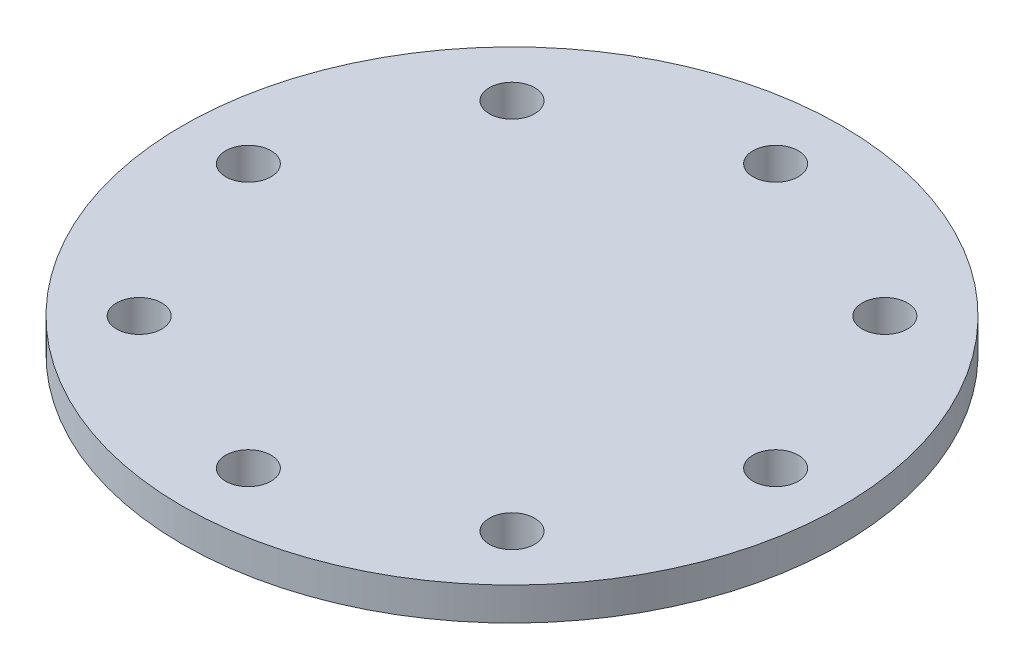
from build123d import *

# Parameters (mm, degrees)
SKETCH2_R                       = 127
EXTRUDE1_DEPTH                  = 12.7
F_11_16_0_6875_DIAMETER_HOLE1_D = 17.4625
CIRPATTERN1_COUNT               = 8


with BuildPart() as part:
    # Sketch2 → Extrude1 (new body)
    with BuildSketch(Plane(origin=(0, 0, 0), x_dir=(1, 0, 0), z_dir=(0, 1, 0))):
        Circle(SKETCH2_R)
    extrude(amount=EXTRUDE1_DEPTH)

    # 11_16 _0.6875_ Diameter Hole1 (through all)
    with Locations(Plane(origin=(0, 12.7, 0), x_dir=(-1, 0, 0), z_dir=(0, 1, 0))):
        with Locations((-101.6, 0)):
            f_11_16_0_6875_diameter_hole1 = Hole(F_11_16_0_6875_DIAMETER_HOLE1_D / 2)

    # CirPattern1: 11_16 _0.6875_ Diameter Hole1 ×8 about axis
    cirpattern1_axis = Axis((0, 12.7, 0), (0, -1, 0))
    for i in range(1, CIRPATTERN1_COUNT):
        add(f_11_16_0_6875_diameter_hole1.rotate(cirpattern1_axis, i * 360 / CIRPATTERN1_COUNT), mode=Mode.SUBTRACT)


solid = part.part
